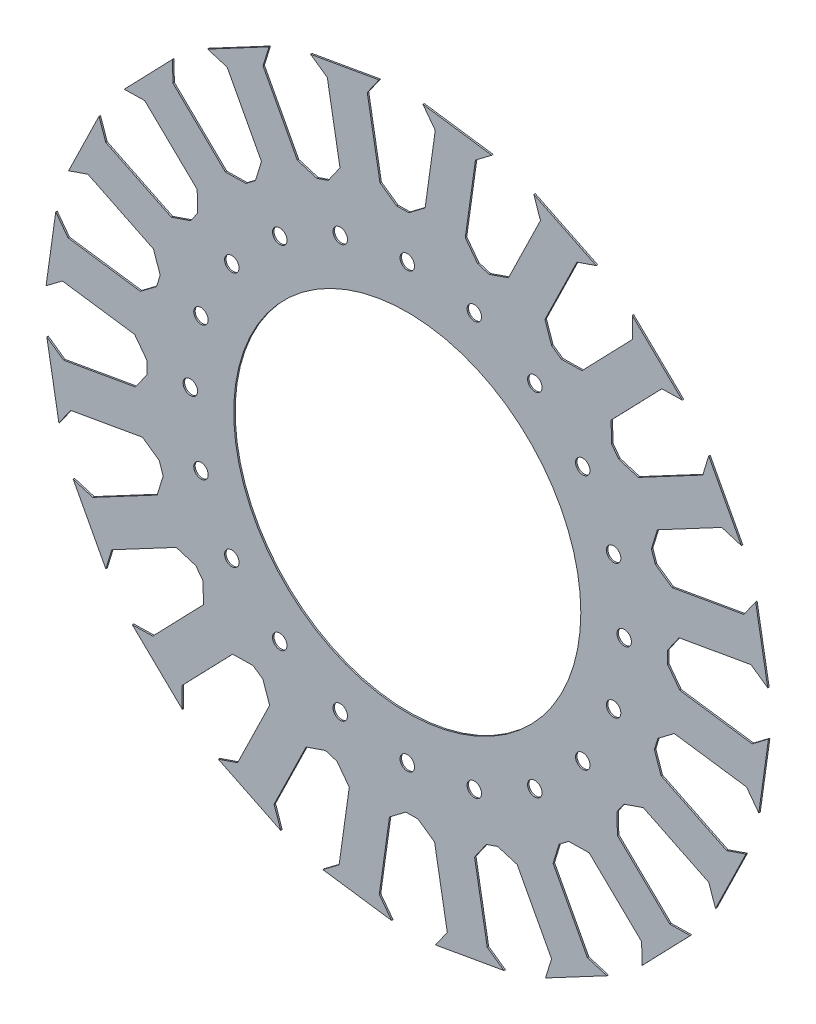
from build123d import *

# Parameters (mm, degrees)
Y_KSEKLIK_EKSTR_ZYON1_DEPTH = 1
IZIM2_R                     = 60
KES_EKSTR_ZYON1_DEPTH       = 1
IZIM3_R                     = 2.5
KES_EKSTR_ZYON2_DEPTH       = 1
IZIM5_R                     = 82.296906758
IZIM5_R_2                   = 60
Y_KSEKLIK_EKSTR_ZYON4_DEPTH = 1
IZIM6_R                     = 2.5
KES_EKSTR_ZYON3_DEPTH       = 1
IZIM7_R                     = 160.463194487
KES_EKSTR_ZYON4_DEPTH       = 0.5


with BuildPart() as part:
    # Çizim1 → Yükseklik-Ekstrüzyon1 (new body)
    with BuildSketch(Plane.XY):
        Polygon((-3.655966564, 89.925713278), (-1.570294625, 89.962118817), (0.515377314, 89.998524356), (6.162583162, 94.253999195), (9.673478824, 119.235319882), (5.418003985, 124.882525731), (29.214169481, 121.538192769), (23.566963633, 117.28271793), (20.056067971, 92.301397243), (24.31154281, 86.654191394), (26.306384629, 86.044307046), (28.301226447, 85.434422697), (34.987052413, 87.736537195), (46.045765244, 110.410258595), (43.743650746, 117.096084561), (65.341693285, 106.562015365), (58.655867319, 104.259900868), (47.597154488, 81.586179467), (49.899268986, 74.900353502), (51.608011668, 73.703878995), (53.31675435, 72.507404488), (60.386745204, 72.630811638), (77.910771342, 90.777471923), (77.787364193, 97.847462777), (95.073116887, 81.154805437), (88.003126033, 81.031398287), (70.479099894, 62.884738001), (70.602507044, 55.814747147), (71.85788695, 54.148801743), (73.113266857, 52.482856339), (79.875362635, 50.415476189), (102.149328305, 62.258753816), (104.216708455, 69.020849594), (115.498121395, 47.803597713), (108.736025616, 49.870977863), (86.462059946, 38.027700236), (84.394679796, 31.265604458), (85.073811595, 29.2932625), (85.752943394, 27.320920542), (91.545223047, 23.265122665), (116.388797298, 27.645715103), (120.444595174, 33.437994756), (124.617365058, 9.773040778), (118.825085404, 13.828838655), (93.981511154, 9.448246217), (89.925713278, 3.655966564), (89.962118817, 1.570294625), (89.998524356, -0.515377314), (94.253999195, -6.162583162), (119.235319882, -9.673478823), (124.882525731, -5.418003985), (121.538192769, -29.214169481), (117.28271793, -23.566963633), (92.301397243, -20.056067971), (86.654191394, -24.31154281), (86.044307046, -26.306384629), (85.434422697, -28.301226447), (87.736537195, -34.987052413), (110.410258595, -46.045765244), (117.096084561, -43.743650746), (106.562015365, -65.341693284), (104.259900868, -58.655867319), (81.586179467, -47.597154488), (74.900353502, -49.899268986), (73.703878995, -51.608011668), (72.507404488, -53.31675435), (72.630811638, -60.386745204), (90.777471923, -77.910771342), (97.847462777, -77.787364193), (81.154805437, -95.073116887), (81.031398287, -88.003126033), (62.884738001, -70.479099894), (55.814747147, -70.602507044), (54.148801743, -71.85788695), (52.482856339, -73.113266857), (50.415476189, -79.875362635), (62.258753816, -102.149328305), (69.020849594, -104.216708455), (47.803597713, -115.498121395), (49.870977863, -108.736025616), (38.027700236, -86.462059946), (31.265604458, -84.394679796), (29.2932625, -85.073811595), (27.320920542, -85.752943394), (23.265122665, -91.545223047), (27.645715103, -116.388797297), (33.437994756, -120.444595174), (9.773040778, -124.617365058), (13.828838655, -118.825085404), (9.448246217, -93.981511154), (3.655966564, -89.925713278), (1.570294625, -89.962118817), (-0.515377314, -89.998524356), (-6.162583162, -94.253999195), (-9.673478823, -119.235319882), (-5.418003985, -124.88252573), (-29.214169481, -121.538192769), (-23.566963633, -117.28271793), (-20.056067971, -92.301397243), (-24.31154281, -86.654191394), (-26.306384629, -86.044307046), (-28.301226447, -85.434422697), (-34.987052413, -87.736537195), (-46.045765244, -110.410258595), (-43.743650746, -117.096084561), (-65.341693284, -106.562015365), (-58.655867319, -104.259900868), (-47.597154488, -81.586179467), (-49.899268986, -74.900353502), (-51.608011668, -73.703878995), (-53.31675435, -72.507404488), (-60.386745204, -72.630811638), (-77.910771342, -90.777471923), (-77.787364193, -97.847462777), (-95.073116887, -81.154805437), (-88.003126033, -81.031398287), (-70.479099894, -62.884738001), (-70.602507044, -55.814747147), (-71.85788695, -54.148801743), (-73.113266857, -52.482856339), (-79.875362635, -50.415476189), (-102.149328305, -62.258753816), (-104.216708455, -69.020849594), (-115.498121395, -47.803597713), (-108.736025616, -49.870977863), (-86.462059946, -38.027700236), (-84.394679796, -31.265604458), (-85.073811595, -29.2932625), (-85.752943394, -27.320920542), (-91.545223047, -23.265122665), (-116.388797297, -27.645715103), (-120.444595174, -33.437994756), (-124.617365058, -9.773040778), (-118.825085404, -13.828838655), (-93.981511154, -9.448246217), (-89.925713278, -3.655966564), (-89.962118817, -1.570294625), (-89.998524356, 0.515377314), (-94.253999195, 6.162583162), (-119.235319882, 9.673478824), (-124.88252573, 5.418003985), (-121.538192769, 29.214169481), (-117.28271793, 23.566963633), (-92.301397243, 20.056067971), (-86.654191394, 24.31154281), (-86.044307046, 26.306384629), (-85.434422697, 28.301226447), (-87.736537195, 34.987052413), (-110.410258595, 46.045765244), (-117.096084561, 43.743650746), (-106.562015365, 65.341693284), (-104.259900868, 58.655867319), (-81.586179467, 47.597154488), (-74.900353502, 49.899268986), (-73.703878995, 51.608011668), (-72.507404488, 53.31675435), (-72.630811638, 60.386745204), (-90.777471923, 77.910771342), (-97.847462777, 77.787364193), (-81.154805437, 95.073116887), (-81.031398287, 88.003126033), (-62.884738001, 70.479099894), (-55.814747147, 70.602507044), (-54.148801743, 71.85788695), (-52.482856339, 73.113266857), (-50.415476189, 79.875362635), (-62.258753816, 102.149328305), (-69.020849594, 104.216708455), (-47.803597713, 115.498121395), (-49.870977863, 108.736025616), (-38.027700236, 86.462059946), (-31.265604458, 84.394679796), (-29.2932625, 85.073811595), (-27.320920542, 85.752943394), (-23.265122665, 91.545223047), (-27.645715103, 116.388797298), (-33.437994756, 120.444595174), (-9.773040778, 124.617365058), (-13.828838655, 118.825085404), (-9.448246217, 93.981511154), align=None)
    extrude(amount=Y_KSEKLIK_EKSTR_ZYON1_DEPTH)

    # Çizim2 → Kes-Ekstrüzyon1 (cut)
    with BuildSketch(Plane.XY.offset(1)):
        Circle(IZIM2_R)
    extrude(amount=-KES_EKSTR_ZYON1_DEPTH, mode=Mode.SUBTRACT)

    # Çizim3 → Kes-Ekstrüzyon2 (cut)
    with BuildSketch(Plane.XY.offset(1)):
        with Locations((37.5, 64.951905284)):
            Circle(IZIM3_R)
        with Locations((0, 75)):
            Circle(IZIM3_R)
        with Locations((64.951905284, 37.5)):
            Circle(IZIM3_R)
        with Locations((75, 0)):
            Circle(IZIM3_R)
        with Locations((64.951905284, -37.5)):
            Circle(IZIM3_R)
        with Locations((37.5, -64.951905284)):
            Circle(IZIM3_R)
        with Locations((0, -75)):
            Circle(IZIM3_R)
        with Locations((-37.5, -64.951905284)):
            Circle(IZIM3_R)
        with Locations((-64.951905284, -37.5)):
            Circle(IZIM3_R)
        with Locations((-75, 0)):
            Circle(IZIM3_R)
        with Locations((-64.951905284, 37.5)):
            Circle(IZIM3_R)
        with Locations((-37.5, 64.951905284)):
            Circle(IZIM3_R)
    extrude(amount=-KES_EKSTR_ZYON2_DEPTH, mode=Mode.SUBTRACT)

    # Çizim5 → Yükseklik-Ekstrüzyon4 (add)
    with BuildSketch(Plane.XY.offset(1)):
        Circle(IZIM5_R)
        Circle(IZIM5_R_2, mode=Mode.SUBTRACT)
    extrude(amount=-Y_KSEKLIK_EKSTR_ZYON4_DEPTH)

    # Çizim6 → Kes-Ekstrüzyon3 (cut)
    with BuildSketch(Plane.XY.offset(1)):
        with Locations((23.176274578, 71.329238722)):
            Circle(IZIM6_R)
        with Locations((0, 75)):
            Circle(IZIM6_R)
        with Locations((44.083893922, 60.676274578)):
            Circle(IZIM6_R)
        with Locations((60.676274578, 44.083893922)):
            Circle(IZIM6_R)
        with Locations((71.329238722, 23.176274578)):
            Circle(IZIM6_R)
        with Locations((75, 0)):
            Circle(IZIM6_R)
        with Locations((71.329238722, -23.176274578)):
            Circle(IZIM6_R)
        with Locations((60.676274578, -44.083893922)):
            Circle(IZIM6_R)
        with Locations((44.083893922, -60.676274578)):
            Circle(IZIM6_R)
        with Locations((23.176274578, -71.329238722)):
            Circle(IZIM6_R)
        with Locations((0, -75)):
            Circle(IZIM6_R)
        with Locations((-23.176274578, -71.329238722)):
            Circle(IZIM6_R)
        with Locations((-44.083893922, -60.676274578)):
            Circle(IZIM6_R)
        with Locations((-60.676274578, -44.083893922)):
            Circle(IZIM6_R)
        with Locations((-71.329238722, -23.176274578)):
            Circle(IZIM6_R)
        with Locations((-75, 0)):
            Circle(IZIM6_R)
        with Locations((-71.329238722, 23.176274578)):
            Circle(IZIM6_R)
        with Locations((-60.676274578, 44.083893922)):
            Circle(IZIM6_R)
        with Locations((-44.083893922, 60.676274578)):
            Circle(IZIM6_R)
        with Locations((-23.176274578, 71.329238722)):
            Circle(IZIM6_R)
    extrude(amount=-KES_EKSTR_ZYON3_DEPTH, mode=Mode.SUBTRACT)

    # Çizim7 → Kes-Ekstrüzyon4 (cut)
    with BuildSketch(Plane.XY.offset(1)):
        Circle(IZIM7_R)
    extrude(amount=-KES_EKSTR_ZYON4_DEPTH, mode=Mode.SUBTRACT)


solid = part.part
